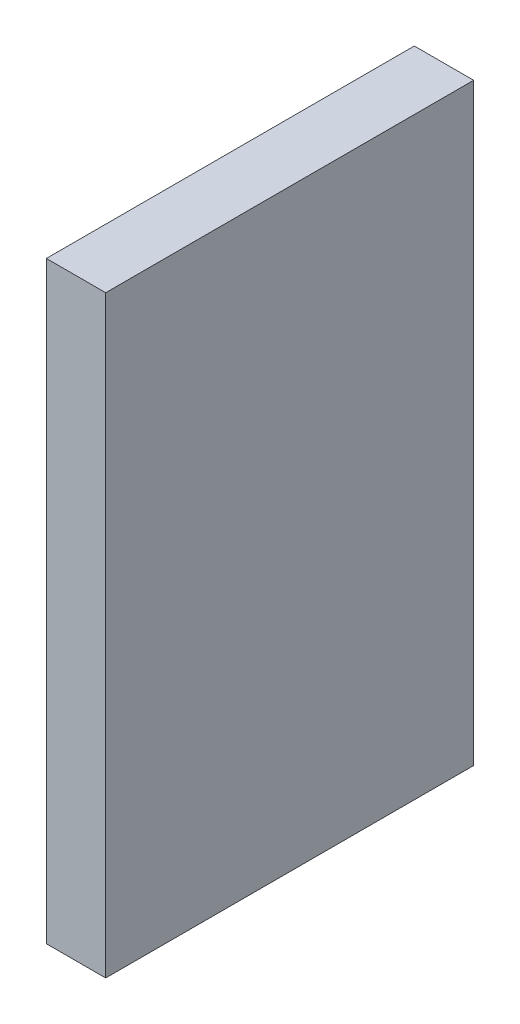
from build123d import *

# Parameters (mm, degrees)
CROQUIS1_W              = 18.6
CROQUIS1_H              = 30
SALIENTE_EXTRUIR1_DEPTH = 3


with BuildPart() as part:
    # Croquis1 → Saliente-Extruir1 (new body)
    with BuildSketch(Plane(origin=(0, 0, 0), x_dir=(0, 0, -1), z_dir=(1, 0, 0))):
        with Locations((0.397738086, 0.795476171)):
            Rectangle(CROQUIS1_W, CROQUIS1_H)
    extrude(amount=SALIENTE_EXTRUIR1_DEPTH)


solid = part.part
